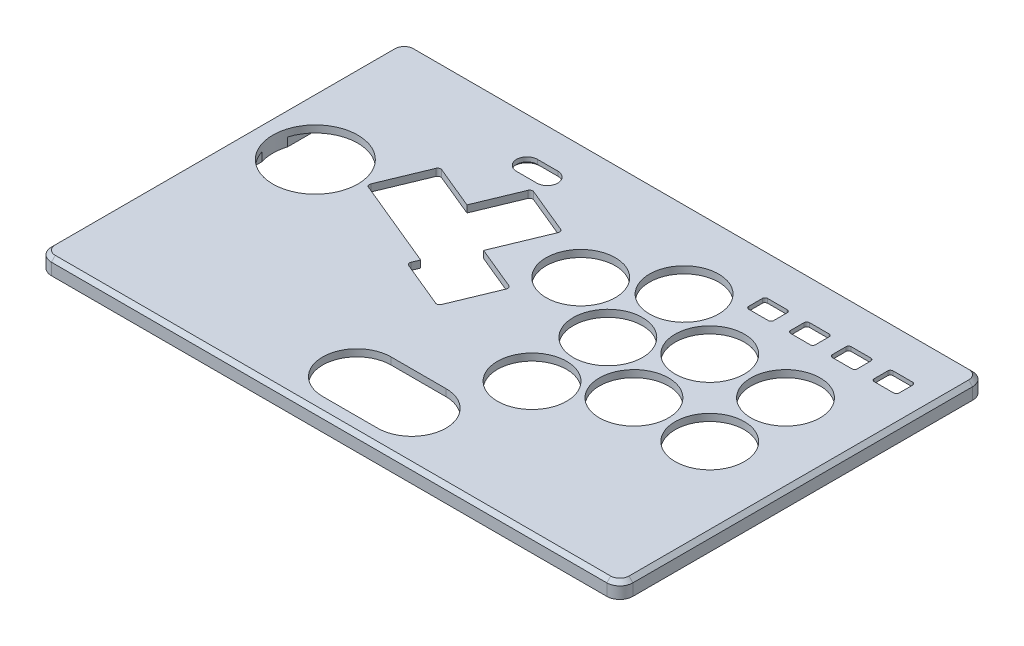
from build123d import *

# Parameters (mm, degrees)
SKETCH1_W                = 222.53
SKETCH1_H                = 140
TOP_PLATE_DEPTH          = 6
CORNER_FILLET_R          = 5
M3_CLEARANCE_HOLE1_D     = 3.4
M3_CLEARANCE_HOLE1_DEPTH = 4.228536948
M3_CLEARANCE_HOLE1_TIP   = 1.021463052
SKETCH4_R                = 16.25
SKETCH4_R_2              = 13.25
PRIMARY_BUTTONS_DEPTH    = 10
EXTRA_BUTTONS_REACH      = 8
SKETCH8_W                = 207.53
SKETCH8_H                = 125
HOLLOW_OUT_DEPTH         = 3.3
FILLET1_R                = 10
FILLET2_R                = 5
SKETCH15_W               = 64
SKETCH15_H               = 16
CUT_EXTRUDE4_DEPTH       = 4.4
LIGHT_GUIDE_CUTOUT_DEPTH = 10
CHAMFER1_SIZE            = 1
TOP_CHAMFER_SIZE         = 1.5
NUT_START                = -1.2
NUT_CUTOUT_DEPTH         = 2


with BuildPart() as part:
    # Sketch1 → Top Plate (new body)
    with BuildSketch(Plane(origin=(0, 0, 0), x_dir=(1, 0, 0), z_dir=(0, 1, 0))):
        with Locations((111.265, 70)):
            Rectangle(SKETCH1_W, SKETCH1_H)
    extrude(amount=TOP_PLATE_DEPTH)

    # Corner Fillet
    corner_fillet_edges = [part.edges().sort_by_distance(p)[0] for p in [
        (0, 3, -140),
        (222.53, 3, -140),
        (222.53, 3, 0),
        (0, 3, 0),
    ]]
    fillet(corner_fillet_edges, radius=CORNER_FILLET_R)

    # M3 Clearance Hole1
    with Locations(Plane(origin=(217.03, 0, -5.5), x_dir=(0, 0, -1), z_dir=(0, -1, 0))):
        with Locations((0, 0), (129, 0), (129, -211.53), (0, -211.53)):
            Hole(M3_CLEARANCE_HOLE1_D / 2, depth=M3_CLEARANCE_HOLE1_DEPTH)
            with Locations((0, 0, -(M3_CLEARANCE_HOLE1_DEPTH + M3_CLEARANCE_HOLE1_TIP / 2))):  # 118° drill point
                Cone(0, M3_CLEARANCE_HOLE1_D / 2, M3_CLEARANCE_HOLE1_TIP, mode=Mode.SUBTRACT)

    # Sketch4 → Primary Buttons (cut)
    with BuildSketch(Plane(origin=(0, 6, 0), x_dir=(-1, 0, 0), z_dir=(0, -1, 0))):
        with BuildLine():
            ThreePointArc((-48.971318984, 103.179989332), (-49.620754304, 103.829424652), (-50.539194542, 103.829424652))
            Line((-50.539194542, 103.829424652), (-67.030443813, 96.998525544))
            Line((-67.030443813, 96.998525544), (-73.861342517, 113.489775595))
            ThreePointArc((-73.861342517, 113.489775595), (-74.510777833, 114.139210949), (-75.429218092, 114.139210957))
            Line((-75.429218092, 114.139210957), (-93.029123186, 106.849091571))
            ThreePointArc((-93.029123186, 106.849091571), (-93.678558502, 106.199656261), (-93.678558515, 105.281216033))
            Line((-93.678558515, 105.281216033), (-86.388439374, 87.681310625))
            Line((-86.388439374, 87.681310625), (-85.316925644, 85.094447645))
            Line((-85.316925644, 85.094447645), (-101.80817536, 78.263548352))
            ThreePointArc((-101.80817536, 78.263548352), (-102.457610681, 77.614113031), (-102.457610681, 76.695672794))
            Line((-102.457610681, 76.695672794), (-95.167491294, 59.095767699))
            ThreePointArc((-95.167491294, 59.095767699), (-94.518055974, 58.446332379), (-93.599615736, 58.446332379))
            Line((-93.599615736, 58.446332379), (-75.999710782, 65.736451708))
            ThreePointArc((-75.999710782, 65.736451708), (-75.350275462, 66.385887028), (-75.350275462, 67.304327265))
            Line((-75.350275462, 67.304327265), (-76.421789326, 69.891190568))
            Line((-76.421789326, 69.891190568), (-59.93053937, 76.722089559))
            Line((-59.93053937, 76.722089559), (-42.330634918, 84.01220868))
            ThreePointArc((-42.330634918, 84.01220868), (-41.681199598, 84.661644), (-41.681199598, 85.580084238))
            Line((-41.681199598, 85.580084238), (-48.971318984, 103.179989332))
        make_face()
        with Locations((-23, 83.008304)):
            Circle(SKETCH4_R)
        with Locations((-112.915906, 94.645876)):
            Circle(SKETCH4_R_2)
        with Locations((-138.114257, 108.999439)):
            Circle(SKETCH4_R_2)
        with Locations((-162.933943, 94)):
            Circle(SKETCH4_R_2)
        with Locations((-191.933943, 94)):
            Circle(SKETCH4_R_2)
        with Locations((-137.933943, 80)):
            Circle(SKETCH4_R_2)
        with Locations((-137.933943, 51)):
            Circle(SKETCH4_R_2)
        with Locations((-162.933943, 65)):
            Circle(SKETCH4_R_2)
        with Locations((-191.933943, 65)):
            Circle(SKETCH4_R_2)
        with BuildLine():
            ThreePointArc((-102.903943224, 5.899999517), (-89.803943224, 18.999999517), (-102.903943224, 32.099999517))
            Line((-102.903943224, 32.099999517), (-123.903943224, 32.099999517))
            ThreePointArc((-123.903943224, 32.099999517), (-137.003943224, 18.999999517), (-123.903943224, 5.899999517))
            Line((-123.903943224, 5.899999517), (-102.903943224, 5.899999517))
        make_face()
    extrude(amount=PRIMARY_BUTTONS_DEPTH, mode=Mode.SUBTRACT)

    # Sketch5 → Extra Buttons (cut, up to next)
    with BuildSketch(Plane.XZ, mode=Mode.PRIVATE) as extra_buttons_sk1:
        with BuildLine():
            Line((154.55, -122.52), (154.55, -117.32))
            ThreePointArc((154.55, -117.32), (154.842893219, -116.612893219), (155.55, -116.32))
            Line((155.55, -116.32), (163.05, -116.32))
            ThreePointArc((163.05, -116.32), (163.757106781, -116.612893219), (164.05, -117.32))
            Line((164.05, -117.32), (164.05, -122.52))
            ThreePointArc((164.05, -122.52), (163.757106781, -123.227106781), (163.05, -123.52))
            Line((163.05, -123.52), (155.55, -123.52))
            ThreePointArc((155.55, -123.52), (154.842893219, -123.227106781), (154.55, -122.52))
        make_face()
    extra_buttons_tool1 = extrude(extra_buttons_sk1.sketch, amount=-EXTRA_BUTTONS_REACH, mode=Mode.PRIVATE) & part.part
    add(extra_buttons_tool1.solids().sort_by_distance((159.3, 0, -119.92))[0], mode=Mode.SUBTRACT)
    # Sketch5 → Extra Buttons (cut, up to next)
    with BuildSketch(Plane.XZ, mode=Mode.PRIVATE) as extra_buttons_sk2:
        with BuildLine():
            Line((170.55, -122.52), (170.55, -117.32))
            ThreePointArc((170.55, -117.32), (170.842893219, -116.612893219), (171.55, -116.32))
            Line((171.55, -116.32), (179.05, -116.32))
            ThreePointArc((179.05, -116.32), (179.757106781, -116.612893219), (180.05, -117.32))
            Line((180.05, -117.32), (180.05, -122.52))
            ThreePointArc((180.05, -122.52), (179.757106781, -123.227106781), (179.05, -123.52))
            Line((179.05, -123.52), (171.55, -123.52))
            ThreePointArc((171.55, -123.52), (170.842893219, -123.227106781), (170.55, -122.52))
        make_face()
    extra_buttons_tool2 = extrude(extra_buttons_sk2.sketch, amount=-EXTRA_BUTTONS_REACH, mode=Mode.PRIVATE) & part.part
    add(extra_buttons_tool2.solids().sort_by_distance((175.3, 0, -119.92))[0], mode=Mode.SUBTRACT)
    # Sketch5 → Extra Buttons (cut, up to next)
    with BuildSketch(Plane.XZ, mode=Mode.PRIVATE) as extra_buttons_sk3:
        with BuildLine():
            Line((186.55, -122.52), (186.55, -117.32))
            ThreePointArc((186.55, -117.32), (186.842893219, -116.612893219), (187.55, -116.32))
            Line((187.55, -116.32), (195.05, -116.32))
            ThreePointArc((195.05, -116.32), (195.757106781, -116.612893219), (196.05, -117.32))
            Line((196.05, -117.32), (196.05, -122.52))
            ThreePointArc((196.05, -122.52), (195.757106781, -123.227106781), (195.05, -123.52))
            Line((195.05, -123.52), (187.55, -123.52))
            ThreePointArc((187.55, -123.52), (186.842893219, -123.227106781), (186.55, -122.52))
        make_face()
    extra_buttons_tool3 = extrude(extra_buttons_sk3.sketch, amount=-EXTRA_BUTTONS_REACH, mode=Mode.PRIVATE) & part.part
    add(extra_buttons_tool3.solids().sort_by_distance((191.3, 0, -119.92))[0], mode=Mode.SUBTRACT)
    # Sketch5 → Extra Buttons (cut, up to next)
    with BuildSketch(Plane.XZ, mode=Mode.PRIVATE) as extra_buttons_sk4:
        with BuildLine():
            Line((202.55, -122.52), (202.55, -117.32))
            ThreePointArc((202.55, -117.32), (202.842893219, -116.612893219), (203.55, -116.32))
            Line((203.55, -116.32), (211.05, -116.32))
            ThreePointArc((211.05, -116.32), (211.757106781, -116.612893219), (212.05, -117.32))
            Line((212.05, -117.32), (212.05, -122.52))
            ThreePointArc((212.05, -122.52), (211.757106781, -123.227106781), (211.05, -123.52))
            Line((211.05, -123.52), (203.55, -123.52))
            ThreePointArc((203.55, -123.52), (202.842893219, -123.227106781), (202.55, -122.52))
        make_face()
    extra_buttons_tool4 = extrude(extra_buttons_sk4.sketch, amount=-EXTRA_BUTTONS_REACH, mode=Mode.PRIVATE) & part.part
    add(extra_buttons_tool4.solids().sort_by_distance((207.3, 0, -119.92))[0], mode=Mode.SUBTRACT)

    # Sketch8 → Hollow Out (cut)
    with BuildSketch(Plane.XZ):
        with Locations((111.265, -70)):
            Rectangle(SKETCH8_W, SKETCH8_H)
    extrude(amount=-HOLLOW_OUT_DEPTH, mode=Mode.SUBTRACT)

    # Fillet1
    fillet1_edges = [part.edges().sort_by_distance(p)[0] for p in [
        (7.5, 1.65, -7.5),
        (7.5, 1.65, -132.5),
        (215.03, 1.65, -7.5),
    ]]
    fillet(fillet1_edges, radius=FILLET1_R)

    # Fillet2
    fillet2_edges = [part.edges().sort_by_distance(p)[0] for p in [
        (215.03, 1.65, -132.5),
    ]]
    fillet(fillet2_edges, radius=FILLET2_R)

    # Sketch15 → Cut-Extrude4 (cut)
    with BuildSketch(Plane.XZ):
        with Locations((183.3, -119.92)):
            Rectangle(SKETCH15_W, SKETCH15_H)
    extrude(amount=-CUT_EXTRUDE4_DEPTH, mode=Mode.SUBTRACT)

    # Sketch9 → Light Guide Cutout (cut)
    with BuildSketch(Plane(origin=(0, 6, 0), x_dir=(1, 0, 0), z_dir=(0, 1, 0))):
        with BuildLine():
            Line((65.42, 125.5875), (73.19, 125.5875))
            ThreePointArc((73.19, 125.5875), (77.19, 121.5875), (73.19, 117.5875))
            Line((73.19, 117.5875), (65.42, 117.5875))
            ThreePointArc((65.42, 117.5875), (61.42, 121.5875), (65.42, 125.5875))
        make_face()
    extrude(amount=-LIGHT_GUIDE_CUTOUT_DEPTH, mode=Mode.SUBTRACT)

    # Chamfer1
    chamfer1_edges = [part.edges().sort_by_distance(p)[0] for p in [
        (69.305, 3.3, -117.5875),
        (77.19, 3.3, -121.5875),
        (69.305, 3.3, -125.5875),
        (61.42, 3.3, -121.5875),
    ]]
    chamfer(chamfer1_edges, length=CHAMFER1_SIZE)

    # Top Chamfer
    top_chamfer_edges = [part.edges().sort_by_distance(p)[0] for p in [
        (0, 6, -70),
        (111.265, 6, -140),
        (111.265, 6, 0),
        (222.53, 6, -70),
        (221.065533906, 6, -1.464466094),
        (221.065533906, 6, -138.535533906),
        (1.464466094, 6, -1.464466094),
        (1.464466094, 6, -138.535533906),
    ]]
    chamfer(top_chamfer_edges, length=TOP_CHAMFER_SIZE)

    # Sketch11 → Nut Cutout (cut)
    with BuildSketch(Plane.XZ.offset(NUT_START)):
        Polygon((217.03, -138.601219331), (212.928780669, -134.5), (217.03, -130.398780669), (221.131219331, -134.5), align=None)
        Polygon((1.398780669, -134.5), (5.5, -130.398780669), (9.601219331, -134.5), (5.5, -138.601219331), align=None)
        Polygon((5.5, -9.601219331), (1.398780669, -5.5), (5.5, -1.398780669), (9.601219331, -5.5), align=None)
        Polygon((217.03, -9.601219331), (212.928780669, -5.5), (217.03, -1.398780669), (221.131219331, -5.5), align=None)
    extrude(amount=-NUT_CUTOUT_DEPTH, mode=Mode.SUBTRACT)


solid = part.part
